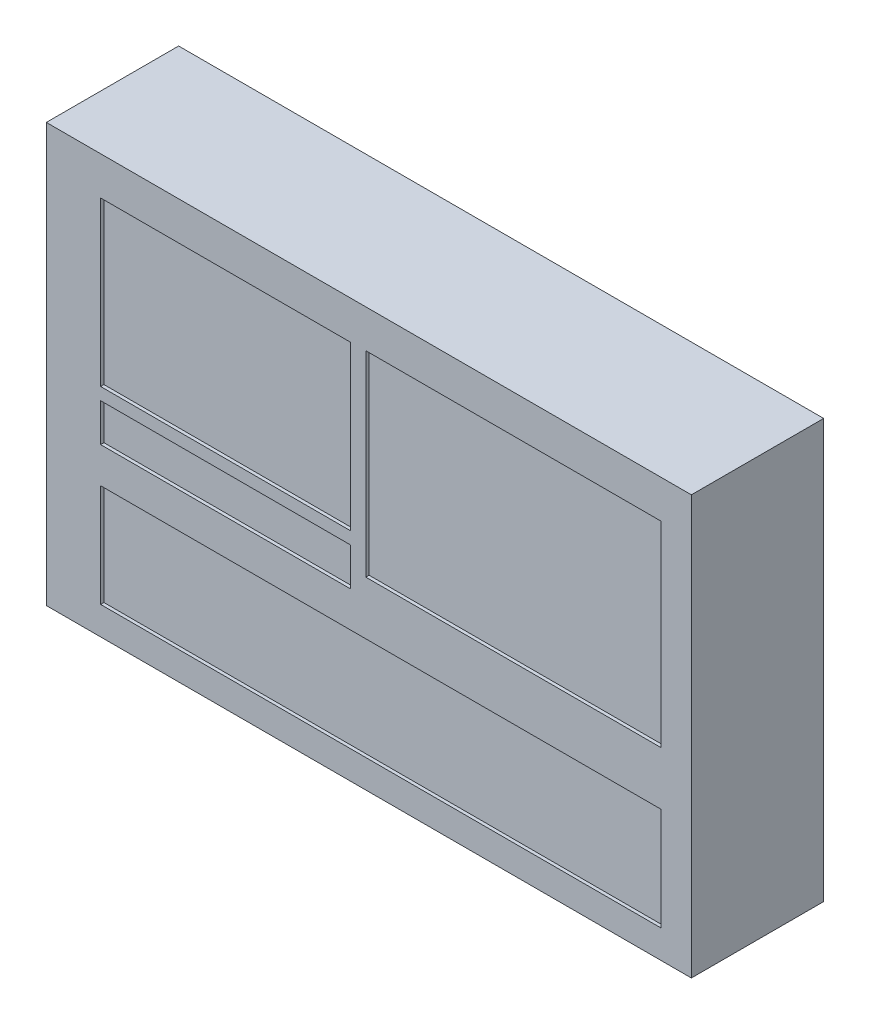
from build123d import *

# Parameters (mm, degrees)
SKETCH1_W           = 390
SKETCH1_H           = 253
BOSS_EXTRUDE1_DEPTH = 80
SKETCH2_W           = 151.227830944
SKETCH2_H           = 98.71559026
SKETCH2_W_2         = 178.5045072
SKETCH2_H_2         = 118.570041685
SKETCH2_W_3         = 338.824563562
SKETCH2_H_3         = 62.161132964
SKETCH2_H_4         = 23.008896977
CUT_EXTRUDE1_DEPTH  = 2


with BuildPart() as part:
    # Sketch1 → Boss-Extrude1 (new body)
    with BuildSketch(Plane.XY):
        with Locations((-77.368932039, 0.975728155)):
            Rectangle(SKETCH1_W, SKETCH1_H)
    extrude(amount=BOSS_EXTRUDE1_DEPTH)

    # Sketch2 → Cut-Extrude1 (cut)
    with BuildSketch(Plane.XY.offset(80)):
        with Locations((-163.930629137, 54.972413805)):
            Rectangle(SKETCH2_W, SKETCH2_H)
        with Locations((10.027765353, 45.230743714)):
            Rectangle(SKETCH2_W_2, SKETCH2_H_2)
        with Locations((-70.132262828, -77.421521628)):
            Rectangle(SKETCH2_W_3, SKETCH2_H_3)
        with Locations((-163.930629137, -13.312054645)):
            Rectangle(SKETCH2_W, SKETCH2_H_4)
    extrude(amount=-CUT_EXTRUDE1_DEPTH, mode=Mode.SUBTRACT)


solid = part.part
